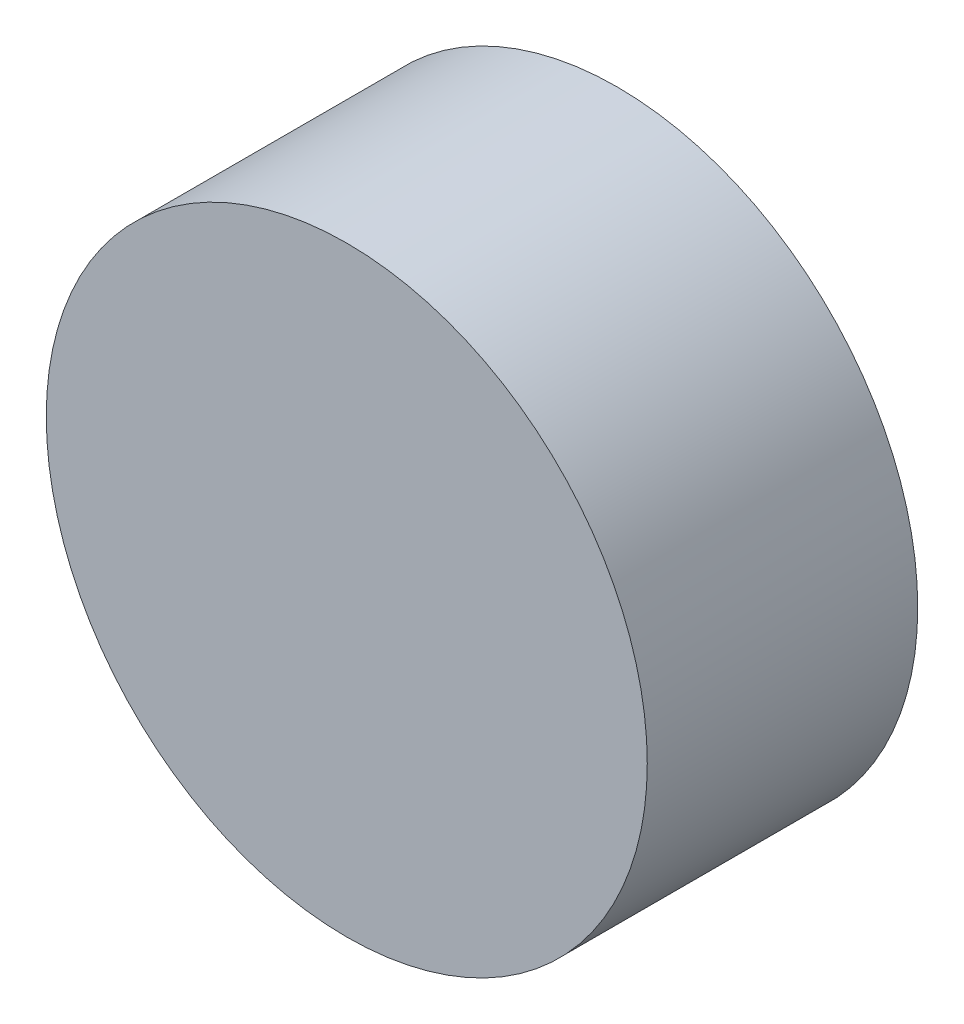
from build123d import *

# Parameters (mm, degrees)
SKETCH_1_R      = 20
EXTRUDE_1_DEPTH = 18


with BuildPart() as part:
    # 草图1 → 凸台-拉伸1 (new body)
    with BuildSketch(Plane.XY):
        Circle(SKETCH_1_R)
    extrude(amount=EXTRUDE_1_DEPTH)


solid = part.part
